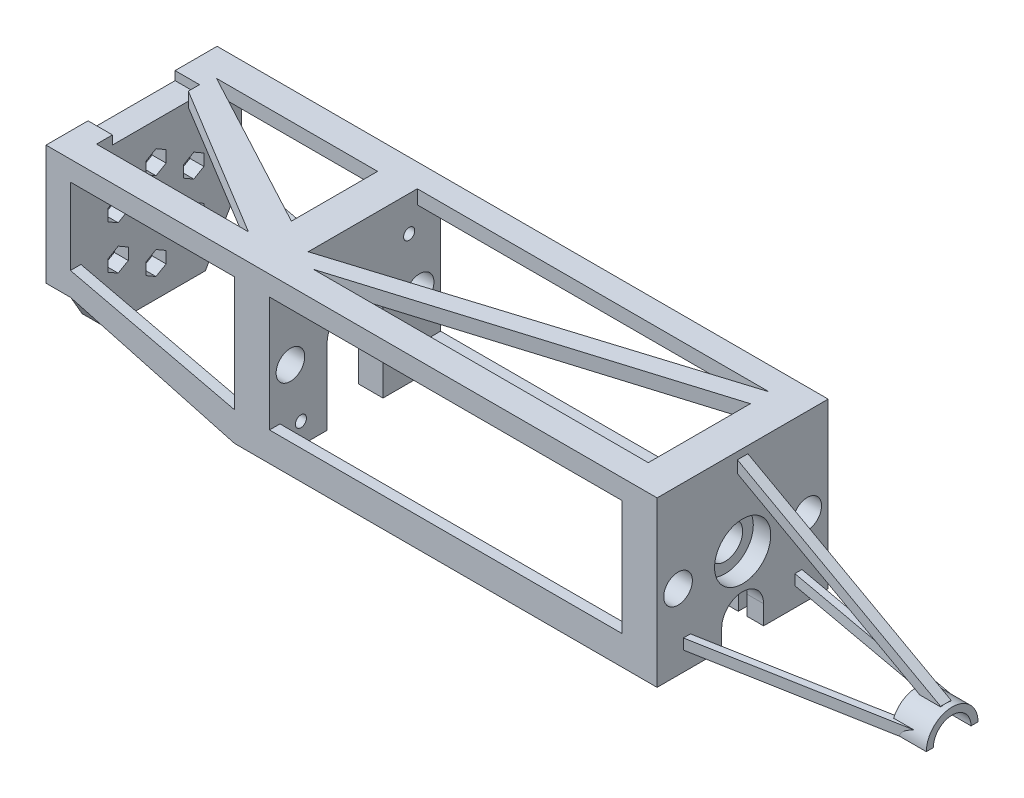
from build123d import *

# Parameters (mm, degrees)
SKETCH1_W           = 175
SKETCH1_H           = 43
BOSS_EXTRUDE1_DEPTH = 4
SKETCH1_3_W         = 7
SKETCH1_3_H         = 43
SKETCH1_3_W_2       = 10
BOSS_EXTRUDE2_DEPTH = 43
SKETCH2_W           = 24.921803412
SKETCH2_H           = 2.5
SKETCH2_R           = 1.55
CUT_EXTRUDE1_DEPTH  = 43
SKETCH3_R           = 4.1
SKETCH3_R_2         = 1.6
CUT_EXTRUDE2_DEPTH  = 43
SKETCH4_R           = 4.1
SKETCH4_R_2         = 5
CUT_EXTRUDE3_DEPTH  = 43
SKETCH4_3_R         = 8.05
SKETCH4_3_R_2       = 5
CUT_EXTRUDE4_DEPTH  = 5
SKETCH6_W           = 101
SKETCH6_H           = 32.974785191
BOSS_EXTRUDE3_DEPTH = 3
CUT_EXTRUDE6_DEPTH  = 1.25
CUT_EXTRUDE7_DEPTH  = 3
CUT_EXTRUDE8_DEPTH  = 4
SKETCH4_4_R         = 4.1
CUT_EXTRUDE9_DEPTH  = 150
BOSS_EXTRUDE4_DEPTH = 60
CUT_EXTRUDE10_DEPTH = 50
BOSS_EXTRUDE5_DEPTH = 1.5
BOSS_EXTRUDE6_DEPTH = 3


with BuildPart() as part:
    # Sketch1 → Boss-Extrude1 (new body)
    with BuildSketch(Plane(origin=(0, 0, 0), x_dir=(1, 0, 0), z_dir=(0, 1, 0))):
        Rectangle(SKETCH1_W, SKETCH1_H)
        Polygon((-80.5, -17.02423389), (-80.5, 9.251394926), (-36.98536512, -17.02423389), align=None, mode=Mode.SUBTRACT)
        Polygon((-79.616903449, 16.459632181), (-33.5, 16.459632181), (-33.5, -8.231428571), align=None, mode=Mode.SUBTRACT)
        Polygon((-23.5, -13.411203118), (-23.5, 17.839340837), (77.209154002, 17.839340837), align=None, mode=Mode.SUBTRACT)
        Polygon((-18.39852542, -17.02423389), (77.5, 12.216270532), (77.5, -17.02423389), align=None, mode=Mode.SUBTRACT)
    extrude(amount=BOSS_EXTRUDE1_DEPTH)

    # Sketch1_3 → Boss-Extrude2 (add)
    with BuildSketch(Plane(origin=(0, 0, 0), x_dir=(1, 0, 0), z_dir=(0, 1, 0))):
        with Locations((-84, 0)):
            Rectangle(SKETCH1_3_W, SKETCH1_3_H)
        with Locations((-28.5, 0)):
            Rectangle(SKETCH1_3_W_2, SKETCH1_3_H)
        with Locations((82.5, 0)):
            Rectangle(SKETCH1_3_W_2, SKETCH1_3_H)
    extrude(amount=-BOSS_EXTRUDE2_DEPTH)

    # Sketch2 → Cut-Extrude1 (cut)
    with BuildSketch(Plane(origin=(-80.5, 0, 0), x_dir=(0, 0, -1), z_dir=(1, 0, 0))):
        Polygon((21.5, -43), (21.5, -30.260907637), (14.145081595, -43), align=None)
        Polygon((-21.5, -43), (-14.145081595, -43), (-21.5, -30.260907637), align=None)
        with Locations((0, 2.75)):
            Rectangle(SKETCH2_W, SKETCH2_H)
        with Locations((-10.825317547, -15.25)):
            Circle(SKETCH2_R)
        with Locations((0, -9)):
            Circle(SKETCH2_R)
        with Locations((10.825317547, -15.25)):
            Circle(SKETCH2_R)
        with Locations((10.825317547, -27.75)):
            Circle(SKETCH2_R)
        with Locations((0, -34)):
            Circle(SKETCH2_R)
        with Locations((-10.825317547, -27.75)):
            Circle(SKETCH2_R)
    extrude(amount=-CUT_EXTRUDE1_DEPTH, mode=Mode.SUBTRACT)

    # Sketch3 → Cut-Extrude2 (cut)
    with BuildSketch(Plane(origin=(-23.5, 0, 0), x_dir=(0, 0, -1), z_dir=(1, 0, 0))):
        with BuildLine():
            Line((-8, -43), (8, -43))
            Line((8, -43), (8, -21.5))
            ThreePointArc((8, -21.5), (0, -13.5), (-8, -21.5))
            Line((-8, -21.5), (-8, -43))
        make_face()
        with Locations((18.5, -21.5)):
            Circle(SKETCH3_R)
        with Locations((-18.5, -21.5)):
            Circle(SKETCH3_R)
        with Locations((15.5, -37)):
            Circle(SKETCH3_R_2)
        with Locations((15.5, -6)):
            Circle(SKETCH3_R_2)
        with Locations((-15.5, -6)):
            Circle(SKETCH3_R_2)
        with Locations((-15.5, -37)):
            Circle(SKETCH3_R_2)
    extrude(amount=-CUT_EXTRUDE2_DEPTH, mode=Mode.SUBTRACT)

    # Sketch4 → Cut-Extrude3 (cut)
    with BuildSketch(Plane(origin=(87.5, 0, 0), x_dir=(0, 0, -1), z_dir=(1, 0, 0))):
        with BuildLine():
            Line((-6, -43), (6, -43))
            Line((6, -43), (6, -37.5))
            ThreePointArc((6, -37.5), (0, -31.5), (-6, -37.5))
            Line((-6, -37.5), (-6, -43))
        make_face()
        with BuildLine():
            ThreePointArc((21.5, -18.705362278), (16.998334258, -17.684898429), (14.4, -21.5))
            ThreePointArc((14.4, -21.5), (16.998334258, -25.315101571), (21.5, -24.294637722))
            Line((21.5, -24.294637722), (21.5, -18.705362278))
        make_face()
        with Locations((-18.5, -21.5)):
            Circle(SKETCH4_R)
        with Locations((0, -21.5)):
            Circle(SKETCH4_R_2)
    extrude(amount=-CUT_EXTRUDE3_DEPTH, mode=Mode.SUBTRACT)

    # Sketch4_3 → Cut-Extrude4 (cut)
    with BuildSketch(Plane(origin=(87.5, 0, 0), x_dir=(0, 0, -1), z_dir=(1, 0, 0))):
        with Locations((0, -21.5)):
            Circle(SKETCH4_3_R)
        with Locations((0, -21.5)):
            Circle(SKETCH4_3_R_2, mode=Mode.SUBTRACT)
    extrude(amount=-CUT_EXTRUDE4_DEPTH, mode=Mode.SUBTRACT)

    # Sketch6 → Boss-Extrude3 (add)
    with BuildSketch(Plane(origin=(0, 0, -21.5), x_dir=(-1, 0, 0), z_dir=(0, 0, -1))):
        Polygon((87.5, -30.260907637), (80.5, -30.260907637), (33.5, -43), (23.5, -43), (-77.5, -43), (-87.5, -43), (-87.5, 4), (87.5, 4), align=None)
        with Locations((-27, -18.169210683)):
            Rectangle(SKETCH6_W, SKETCH6_H, mode=Mode.SUBTRACT)
        Polygon((80.5, -23.601473433), (80.5, -1.681818087), (33.5, -1.681818087), (33.5, -34.656603278), align=None, mode=Mode.SUBTRACT)
    boss_extrude3 = extrude(amount=BOSS_EXTRUDE3_DEPTH)

    # Mirror1: Boss-Extrude3 across plane
    add(boss_extrude3.mirror(Plane.XY))

    # Sketch7 → Cut-Extrude6 (cut, symmetric)
    with BuildSketch(Plane(origin=(81.5, 0, 0), x_dir=(0, 0, -1), z_dir=(1, 0, 0))):
        with BuildLine():
            ThreePointArc((12.5, -34.490529316), (12.278204733, -33.856933451), (11.709666808, -33.5))
            Line((11.709666808, -33.5), (1.443160895, -31.162233309))
            ThreePointArc((1.443160895, -31.162233309), (0, -31), (-1.443160895, -31.162233309))
            Line((-1.443160895, -31.162233309), (-11.709666808, -33.5))
            ThreePointArc((-11.709666808, -33.5), (-12.278204733, -33.856933451), (-12.5, -34.490529316))
            Line((-12.5, -34.490529316), (-12.5, -59.657999149))
            Line((-12.5, -59.657999149), (12.5, -59.657999149))
            Line((12.5, -59.657999149), (12.5, -34.490529316))
        make_face()
    extrude(amount=CUT_EXTRUDE6_DEPTH, both=True, mode=Mode.SUBTRACT)

    # Sketch8 → Cut-Extrude7 (cut)
    with BuildSketch(Plane.ZY.offset(33.5)):
        with BuildLine():
            Line((-8, -43), (-8, -29.761355821))
            ThreePointArc((-8, -29.761355821), (0, -33), (8, -29.761355821))
            Line((8, -29.761355821), (8, -43))
            Line((8, -43), (11.5, -43))
            Line((11.5, -43), (11.5, -21.5))
            ThreePointArc((11.5, -21.5), (0, -10), (-11.5, -21.5))
            Line((-11.5, -21.5), (-11.5, -43))
            Line((-11.5, -43), (-8, -43))
        make_face()
    extrude(amount=-CUT_EXTRUDE7_DEPTH, mode=Mode.SUBTRACT)

    # Sketch9 → Cut-Extrude8 (cut)
    with BuildSketch(Plane(origin=(-80.5, 0, 0), x_dir=(0, 0, -1), z_dir=(1, 0, 0))):
        Polygon((-2.9, -32.325684219), (-2.9, -35.674315781), (0, -37.348631561), (2.9, -35.674315781), (2.9, -32.325684219), (0, -30.651368439), align=None)
        Polygon((-10.825317547, -24.401368439), (-13.725317547, -26.075684219), (-13.725317547, -29.424315781), (-10.825317547, -31.098631561), (-7.925317547, -29.424315781), (-7.925317547, -26.075684219), align=None)
        Polygon((-10.825317547, -18.598631561), (-7.925317547, -16.924315781), (-7.925317547, -13.575684219), (-10.825317547, -11.901368439), (-13.725317547, -13.575684219), (-13.725317547, -16.924315781), align=None)
        Polygon((-2.9, -7.325684219), (-2.9, -10.674315781), (0, -12.348631561), (2.9, -10.674315781), (2.9, -7.325684219), (0, -5.651368439), align=None)
        Polygon((7.925317547, -13.575684219), (7.925317547, -16.924315781), (10.825317547, -18.598631561), (13.725317547, -16.924315781), (13.725317547, -13.575684219), (10.825317547, -11.901368439), align=None)
        Polygon((7.925317547, -26.075684219), (7.925317547, -29.424315781), (10.825317547, -31.098631561), (13.725317547, -29.424315781), (13.725317547, -26.075684219), (10.825317547, -24.401368439), align=None)
    extrude(amount=-CUT_EXTRUDE8_DEPTH, mode=Mode.SUBTRACT)

    # Sketch4_4 → Cut-Extrude9 (cut)
    with BuildSketch(Plane(origin=(87.5, 0, 0), x_dir=(0, 0, -1), z_dir=(1, 0, 0))):
        with Locations((18.5, -21.5)):
            Circle(SKETCH4_4_R)
        with Locations((-18.5, -21.5)):
            Circle(SKETCH4_4_R)
    extrude(amount=-CUT_EXTRUDE9_DEPTH, mode=Mode.SUBTRACT)

    # Sketch10 → Boss-Extrude4 (add)
    with BuildSketch(Plane(origin=(87.5, 0, 0), x_dir=(0, 0, -1), z_dir=(1, 0, 0))):
        with BuildLine():
            Line((7.4, -37.5), (5.4, -37.5))
            ThreePointArc((5.4, -37.5), (0, -32.1), (-5.4, -37.5))
            Line((-5.4, -37.5), (-7.4, -37.5))
            ThreePointArc((-7.4, -37.5), (0, -30.1), (7.4, -37.5))
        make_face()
    extrude(amount=BOSS_EXTRUDE4_DEPTH)

    # Sketch10_2 → Cut-Extrude10 (cut)
    with BuildSketch(Plane(origin=(87.5, 0, 0), x_dir=(0, 0, -1), z_dir=(1, 0, 0))):
        with BuildLine():
            Line((7.4, -37.5), (5.4, -37.5))
            ThreePointArc((5.4, -37.5), (0, -32.1), (-5.4, -37.5))
            Line((-5.4, -37.5), (-7.4, -37.5))
            ThreePointArc((-7.4, -37.5), (0, -30.1), (7.4, -37.5))
        make_face()
    extrude(amount=CUT_EXTRUDE10_DEPTH, mode=Mode.SUBTRACT)


with BuildPart() as cut_extrude10_piece_1:
    # of the separate pieces the step leaves, piece 1, a body of its own (cut_extrude10_pieces)
    add(part.part.solids().sort_by_distance((87.5, 4, -24.5))[0])



with BuildPart() as cut_extrude10_piece_2:
    # of the separate pieces the step leaves, piece 2, a body of its own (cut_extrude10_pieces)
    add(part.part.solids().sort_by_distance((137.5, -37.5, 5.4))[0])


with BuildPart() as cut_extrude10_piece_1_1:
    add(cut_extrude10_piece_1.part)

    add(cut_extrude10_piece_2.part)  # Boss-Extrude5 merges Cut-Extrude10 piece 2
    # Sketch12 → Boss-Extrude5 (add, symmetric)
    with BuildSketch(Plane.XY):
        Polygon((87.5, -1.477036856), (139.486039904, -30.1), (139.486039904, -31.1), (145.808486256, -31.1), (145.706039934, -30.1), (87.5, 1.947629303), align=None)
    extrude(amount=BOSS_EXTRUDE5_DEPTH, both=True)

    # Sketch13 → Boss-Extrude6 (add)
    with BuildSketch(Plane.XZ.offset(37.5)):
        Polygon((87.5, -16.981213653), (87.5, -14.94799315), (139.669059549, -5.4), (147.5, -6), align=None)
    boss_extrude6 = extrude(amount=-BOSS_EXTRUDE6_DEPTH)

    # Mirror2: Boss-Extrude6 across plane
    add(boss_extrude6.mirror(Plane.XY))


solid = cut_extrude10_piece_1_1.part
